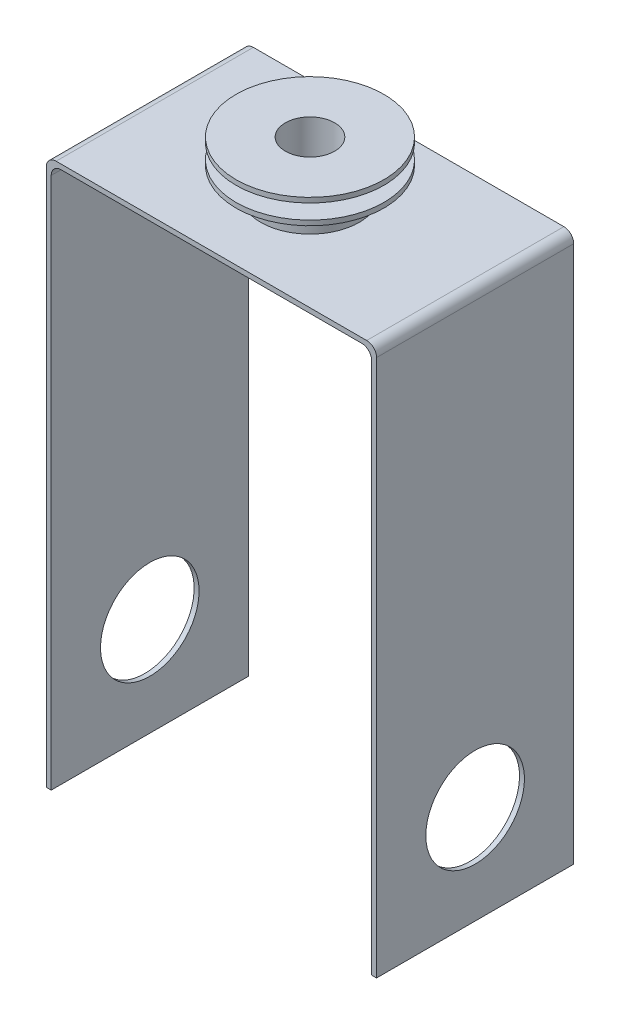
from build123d import *

# Parameters (mm, degrees)
BOSS_EXTRUDE1_DEPTH         = 50.8
SKETCH2_R                   = 12.7
CUT_EXTRUDE1_DEPTH          = 86.09
SKETCH3_R                   = 12.7
BOSS_EXTRUDE2_DEPTH         = 6.35
SKETCH4_R                   = 19.05
BOSS_EXTRUDE3_DEPTH         = 1.27
CUT_EXTRUDE2_REACH          = 150.59
SKETCH5_R                   = 6.35
SKETCH6_R                   = 12.7
BOSS_EXTRUDE4_DEPTH         = 3.81
SKETCH7_R                   = 19.05
BOSS_EXTRUDE5_DEPTH         = 1.27
F_1_16_0_5_DIAMETER_HOLE1_D = 12.7


with BuildPart() as part:
    # Sketch1 → Boss-Extrude1 (new body)
    with BuildSketch(Plane.XY):
        with BuildLine():
            Line((42.545, 113.03), (42.545, -25.4))
            Line((42.545, -25.4), (41.275, -25.4))
            Line((41.275, -25.4), (41.275, 111.76))
            ThreePointArc((41.275, 111.76), (40.531051224, 113.556051224), (38.735, 114.3))
            Line((38.735, 114.3), (-38.735, 114.3))
            ThreePointArc((-38.735, 114.3), (-40.531051224, 113.556051224), (-41.275, 111.76))
            Line((-41.275, 111.76), (-41.275, -25.4))
            Line((-41.275, -25.4), (-42.545, -25.4))
            Line((-42.545, -25.4), (-42.545, 113.03))
            ThreePointArc((-42.545, 113.03), (-41.801051224, 114.826051224), (-40.005, 115.57))
            Line((-40.005, 115.57), (40.005, 115.57))
            ThreePointArc((40.005, 115.57), (41.801051224, 114.826051224), (42.545, 113.03))
        make_face()
    extrude(amount=BOSS_EXTRUDE1_DEPTH)

    # Sketch2 → Cut-Extrude1 (cut, through all)
    with BuildSketch(Plane.ZY.offset(42.545)):
        with Locations((25.4, 0)):
            Circle(SKETCH2_R)
    extrude(amount=-CUT_EXTRUDE1_DEPTH, mode=Mode.SUBTRACT)

    # Sketch3 → Boss-Extrude2 (add)
    with BuildSketch(Plane(origin=(0, 115.57, 0), x_dir=(1, 0, 0), z_dir=(0, 1, 0))):
        with Locations((0, -25.4)):
            Circle(SKETCH3_R)
    extrude(amount=BOSS_EXTRUDE2_DEPTH)

    # Sketch4 → Boss-Extrude3 (add)
    with BuildSketch(Plane(origin=(0, 121.92, 0), x_dir=(1, 0, 0), z_dir=(0, 1, 0))):
        with Locations((0, -25.4)):
            Circle(SKETCH4_R)
    extrude(amount=BOSS_EXTRUDE3_DEPTH)

    # Sketch5 → Cut-Extrude2 (cut, up to next)
    with BuildSketch(Plane(origin=(0, 123.19, 0), x_dir=(1, 0, 0), z_dir=(0, 1, 0)), mode=Mode.PRIVATE) as cut_extrude2_sk1:
        with Locations((0, -25.4)):
            Circle(SKETCH5_R)
    cut_extrude2_tool1 = extrude(cut_extrude2_sk1.sketch, amount=-CUT_EXTRUDE2_REACH, mode=Mode.PRIVATE) & part.part
    add(cut_extrude2_tool1.solids().sort_by_distance((0, 123.19, 25.4))[0], mode=Mode.SUBTRACT)

    # Sketch6 → Boss-Extrude4 (add)
    with BuildSketch(Plane(origin=(0, 123.19, 0), x_dir=(1, 0, 0), z_dir=(0, 1, 0))):
        with Locations((0, -25.4)):
            Circle(SKETCH6_R)
    extrude(amount=BOSS_EXTRUDE4_DEPTH)

    # Sketch7 → Boss-Extrude5 (add)
    with BuildSketch(Plane(origin=(0, 127, 0), x_dir=(1, 0, 0), z_dir=(0, 1, 0))):
        with Locations((0, -25.4)):
            Circle(SKETCH7_R)
    extrude(amount=BOSS_EXTRUDE5_DEPTH)

    # 1/16 (0.5) Diameter Hole1 (through all)
    with Locations(Plane(origin=(0, 128.27, 0), x_dir=(1, 0, 0), z_dir=(0, 1, 0))):
        with Locations((0, -25.4)):
            Hole(F_1_16_0_5_DIAMETER_HOLE1_D / 2)


solid = part.part
